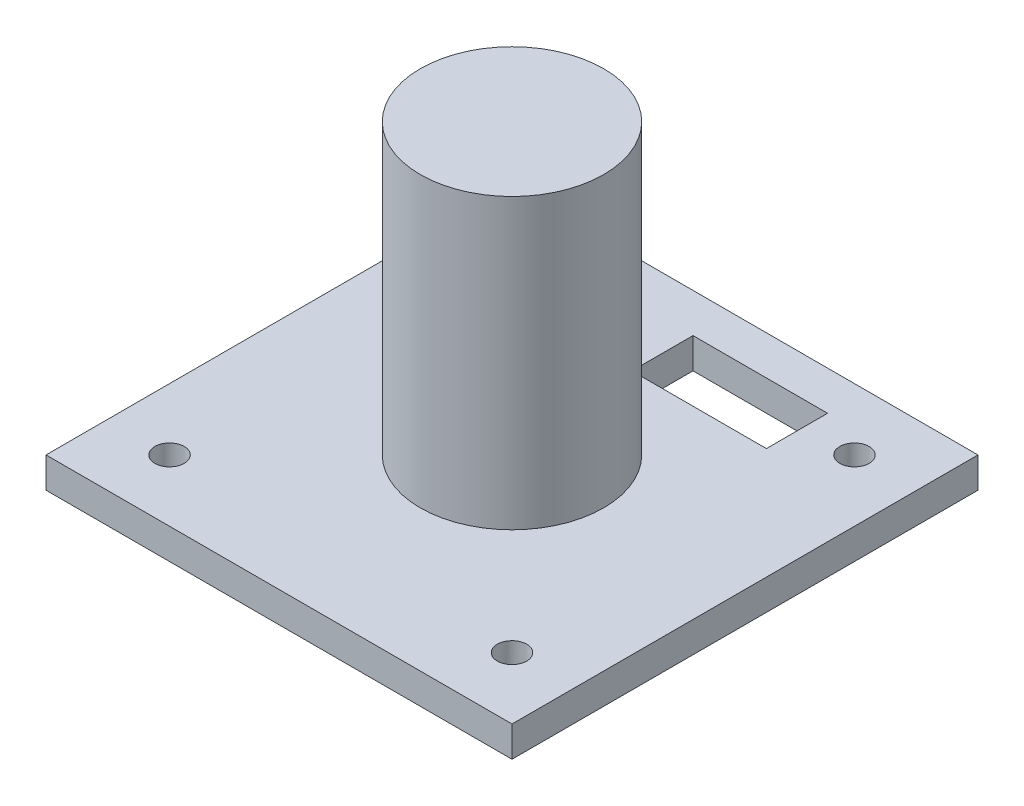
from build123d import *

# Parameters (mm, degrees)
SKETCH1_W           = 38.1
SKETCH1_H           = 38.1
SKETCH1_R           = 1.2
SKETCH1_R_2         = 7.5
SKETCH1_W_2         = 11
SKETCH1_H_2         = 5
BOSS_EXTRUDE1_DEPTH = 2.5
SKETCH1_6_R         = 7.5
BOSS_EXTRUDE2_DEPTH = 26.1


with BuildPart() as part:
    # Sketch1 → Boss-Extrude1 (new body)
    with BuildSketch(Plane(origin=(0, 0, 0), x_dir=(1, 0, 0), z_dir=(0, 1, 0))):
        Rectangle(SKETCH1_W, SKETCH1_H)
        with Locations((-14, -14)):
            Circle(SKETCH1_R, mode=Mode.SUBTRACT)
        with Locations((14, -14)):
            Circle(SKETCH1_R, mode=Mode.SUBTRACT)
        with Locations((-14, 14)):
            Circle(SKETCH1_R, mode=Mode.SUBTRACT)
        Circle(SKETCH1_R_2, mode=Mode.SUBTRACT)
        with Locations((4.45, 13.35)):
            Rectangle(SKETCH1_W_2, SKETCH1_H_2, mode=Mode.SUBTRACT)
        with Locations((14, 14)):
            Circle(SKETCH1_R, mode=Mode.SUBTRACT)
    extrude(amount=BOSS_EXTRUDE1_DEPTH)

    # Sketch1_6 → Boss-Extrude2 (add)
    with BuildSketch(Plane(origin=(0, 0, 0), x_dir=(1, 0, 0), z_dir=(0, 1, 0))):
        Circle(SKETCH1_6_R)
    extrude(amount=BOSS_EXTRUDE2_DEPTH)


solid = part.part
